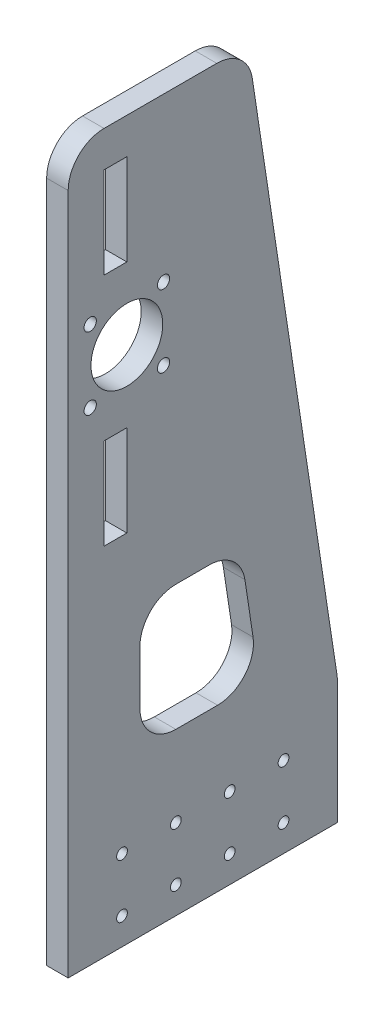
from build123d import *

# Parameters (mm, degrees)
CROQUIS1_R              = 3
CROQUIS1_R_2            = 20
CROQUIS1_R_3            = 3.425181835
CROQUIS1_W              = 12.7
CROQUIS1_H              = 50.8
SALIENTE_EXTRUIR1_DEPTH = 12


with BuildPart() as part:
    # Croquis1 → Saliente-Extruir1 (new body)
    with BuildSketch(Plane(origin=(0, 0, 0), x_dir=(0, 0, -1), z_dir=(1, 0, 0))):
        with BuildLine():
            Line((0, 0), (0, 380))
            ThreePointArc((0, 380), (5.857864376, 394.142135624), (20, 400))
            Line((20, 400), (82.802037251, 400))
            ThreePointArc((82.802037251, 400), (95.841934647, 395.164467544), (102.576347335, 382.996107589))
            Line((102.576347335, 382.996107589), (149.774310084, 71.489553442))
            ThreePointArc((149.774310084, 71.489553442), (149.943497708, 69.995743812), (150, 68.493445854))
            Line((150, 68.493445854), (150, 0))
            Line((150, 0), (0, 0))
        make_face()
        with Locations((30, 45)):
            Circle(CROQUIS1_R, mode=Mode.SUBTRACT)
        with Locations((60, 45)):
            Circle(CROQUIS1_R, mode=Mode.SUBTRACT)
        with Locations((90, 45)):
            Circle(CROQUIS1_R, mode=Mode.SUBTRACT)
        with Locations((120, 45)):
            Circle(CROQUIS1_R, mode=Mode.SUBTRACT)
        with Locations((30, 15)):
            Circle(CROQUIS1_R, mode=Mode.SUBTRACT)
        with Locations((60, 15)):
            Circle(CROQUIS1_R, mode=Mode.SUBTRACT)
        with Locations((90, 15)):
            Circle(CROQUIS1_R, mode=Mode.SUBTRACT)
        with Locations((120, 15)):
            Circle(CROQUIS1_R, mode=Mode.SUBTRACT)
        with Locations((32.7, 289.2)):
            Circle(CROQUIS1_R_2, mode=Mode.SUBTRACT)
        with Locations((12.273774242, 309.320061608)):
            Circle(CROQUIS1_R_3, mode=Mode.SUBTRACT)
        with Locations((53.126225758, 309.320061608)):
            Circle(CROQUIS1_R_3, mode=Mode.SUBTRACT)
        with Locations((53.126225758, 269.079938392)):
            Circle(CROQUIS1_R_3, mode=Mode.SUBTRACT)
        with Locations((12.273774242, 269.079938392)):
            Circle(CROQUIS1_R_3, mode=Mode.SUBTRACT)
        with Locations((26.35, 354.6)):
            Rectangle(CROQUIS1_W, CROQUIS1_H, mode=Mode.SUBTRACT)
        with Locations((26.35, 223.8)):
            Rectangle(CROQUIS1_W, CROQUIS1_H, mode=Mode.SUBTRACT)
        with BuildLine():
            Line((60, 90), (83.2545966, 90))
            ThreePointArc((83.2545966, 90), (98.419064144, 96.960102603), (103.028906685, 112.996107589))
            Line((103.028906685, 112.996107589), (98.483452139, 142.996107589))
            ThreePointArc((98.483452139, 142.996107589), (91.749039451, 155.164467544), (78.709142055, 160))
            Line((78.709142055, 160), (60, 160))
            ThreePointArc((60, 160), (45.857864376, 154.142135624), (40, 140))
            Line((40, 140), (40, 110))
            ThreePointArc((40, 110), (45.857864376, 95.857864376), (60, 90))
        make_face(mode=Mode.SUBTRACT)
    extrude(amount=SALIENTE_EXTRUIR1_DEPTH)


solid = part.part
